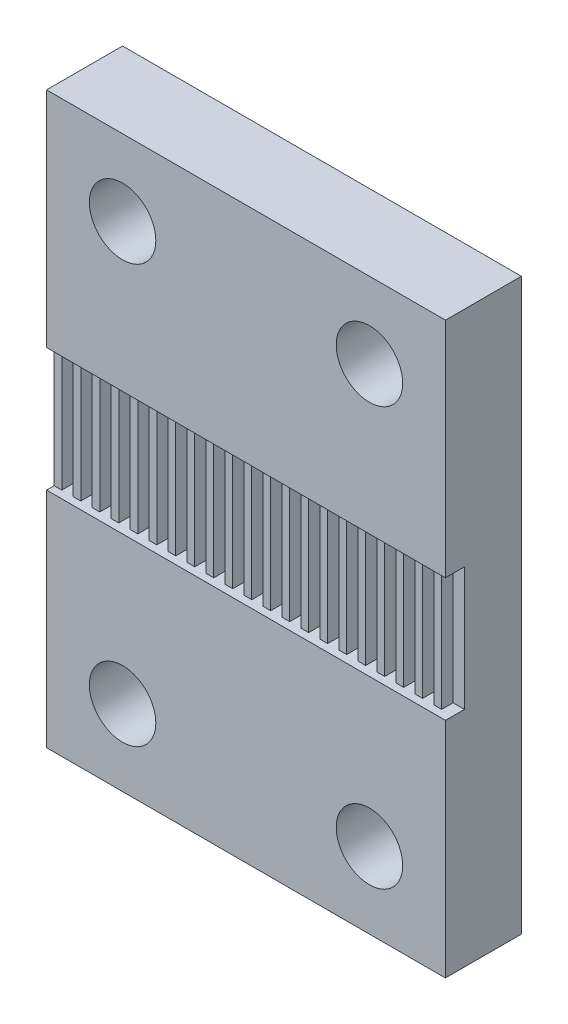
from build123d import *

# Parameters (mm, degrees)
SKETCH1_W           = 21
SKETCH1_H           = 30
SKETCH1_R           = 1.75
BOSS_EXTRUDE1_DEPTH = 4
SKETCH2_W           = 21
SKETCH2_H           = 6.5
CUT_EXTRUDE1_DEPTH  = 1
SKETCH3_W           = 0.4
SKETCH3_H           = 6.5
BOSS_EXTRUDE2_DEPTH = 0.6


with BuildPart() as part:
    # Sketch1 → Boss-Extrude1 (new body)
    with BuildSketch(Plane.XY):
        with Locations((10.5, 15)):
            Rectangle(SKETCH1_W, SKETCH1_H)
        with Locations((4, 4)):
            Circle(SKETCH1_R, mode=Mode.SUBTRACT)
        with Locations((17, 4)):
            Circle(SKETCH1_R, mode=Mode.SUBTRACT)
        with Locations((17, 26)):
            Circle(SKETCH1_R, mode=Mode.SUBTRACT)
        with Locations((4, 26)):
            Circle(SKETCH1_R, mode=Mode.SUBTRACT)
    extrude(amount=BOSS_EXTRUDE1_DEPTH)

    # Sketch2 → Cut-Extrude1 (cut)
    with BuildSketch(Plane.XY.offset(4)):
        with Locations((10.5, 15)):
            Rectangle(SKETCH2_W, SKETCH2_H)
    extrude(amount=-CUT_EXTRUDE1_DEPTH, mode=Mode.SUBTRACT)

    # Sketch3 → Boss-Extrude2 (add)
    with BuildSketch(Plane.XY.offset(3)):
        with Locations((0.2, 15)):
            Rectangle(SKETCH3_W, SKETCH3_H)
        with Locations((1.2, 15)):
            Rectangle(SKETCH3_W, SKETCH3_H)
        with Locations((2.2, 15)):
            Rectangle(SKETCH3_W, SKETCH3_H)
        with Locations((3.2, 15)):
            Rectangle(SKETCH3_W, SKETCH3_H)
        with Locations((4.2, 15)):
            Rectangle(SKETCH3_W, SKETCH3_H)
        with Locations((5.2, 15)):
            Rectangle(SKETCH3_W, SKETCH3_H)
        with Locations((6.2, 15)):
            Rectangle(SKETCH3_W, SKETCH3_H)
        with Locations((7.2, 15)):
            Rectangle(SKETCH3_W, SKETCH3_H)
        with Locations((8.2, 15)):
            Rectangle(SKETCH3_W, SKETCH3_H)
        with Locations((9.2, 15)):
            Rectangle(SKETCH3_W, SKETCH3_H)
        with Locations((10.2, 15)):
            Rectangle(SKETCH3_W, SKETCH3_H)
        with Locations((11.2, 15)):
            Rectangle(SKETCH3_W, SKETCH3_H)
        with Locations((12.2, 15)):
            Rectangle(SKETCH3_W, SKETCH3_H)
        with Locations((13.2, 15)):
            Rectangle(SKETCH3_W, SKETCH3_H)
        with Locations((14.2, 15)):
            Rectangle(SKETCH3_W, SKETCH3_H)
        with Locations((15.2, 15)):
            Rectangle(SKETCH3_W, SKETCH3_H)
        with Locations((16.2, 15)):
            Rectangle(SKETCH3_W, SKETCH3_H)
        with Locations((17.2, 15)):
            Rectangle(SKETCH3_W, SKETCH3_H)
        with Locations((18.2, 15)):
            Rectangle(SKETCH3_W, SKETCH3_H)
        with Locations((19.2, 15)):
            Rectangle(SKETCH3_W, SKETCH3_H)
        with Locations((20.2, 15)):
            Rectangle(SKETCH3_W, SKETCH3_H)
    extrude(amount=BOSS_EXTRUDE2_DEPTH)


solid = part.part
